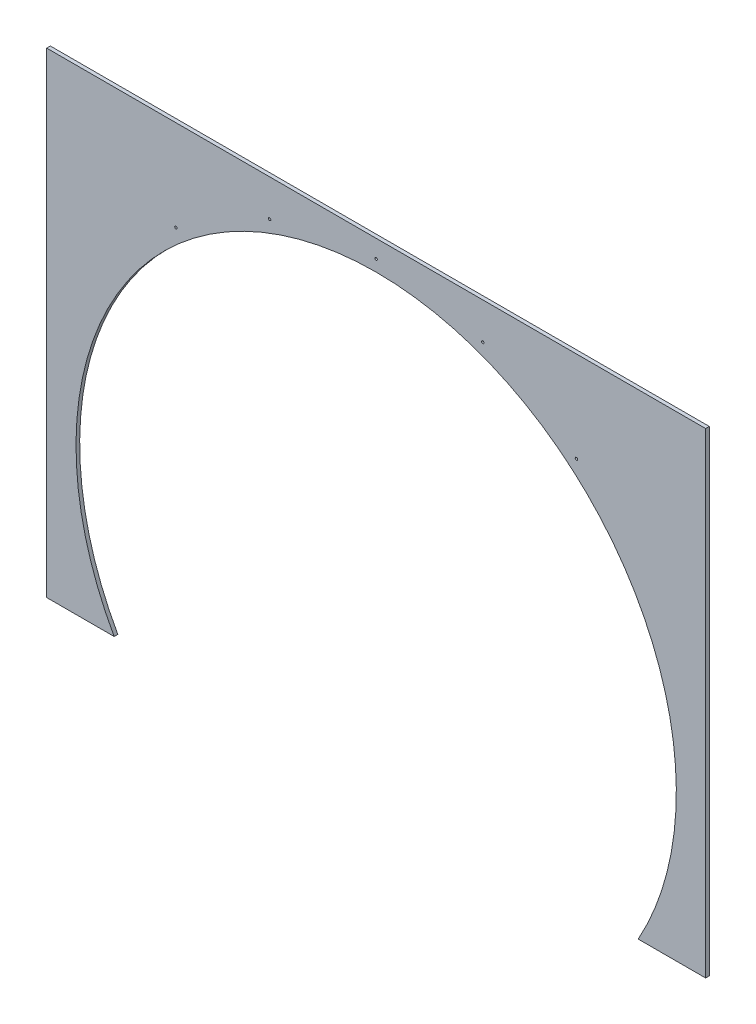
from build123d import *

# Parameters (mm, degrees)
RESSALTO_EXTRUS_O1_DEPTH = 10
FURO_COM_FOLGA_DE_M61_D  = 6.6


with BuildPart() as part:
    # Esboço1 → Ressalto-extrusão1 (new body)
    with BuildSketch(Plane.XY):
        with BuildLine():
            Line((715.821206727, 0), (900, 0))
            Line((900, 0), (900, 1300))
            Line((900, 1300), (-900, 1300))
            Line((-900, 1300), (-900, 0))
            Line((-900, 0), (-715.821206727, 0))
            ThreePointArc((-715.821206727, 0), (0, 1220), (715.821206727, 0))
        make_face()
    extrude(amount=RESSALTO_EXTRUS_O1_DEPTH)

    # Furo com folga de M61 (through all)
    with Locations(Plane(origin=(0, 400, -6), x_dir=(-1, 0, 0), z_dir=(0, 0, -1))):
        with Locations((0, 851.109495843), (291.096591754, 799.781312724), (547.082638414, 651.987699776), (-291.096591754, 799.781312724), (-547.082638414, 651.987699776)):
            Hole(FURO_COM_FOLGA_DE_M61_D / 2)


solid = part.part
